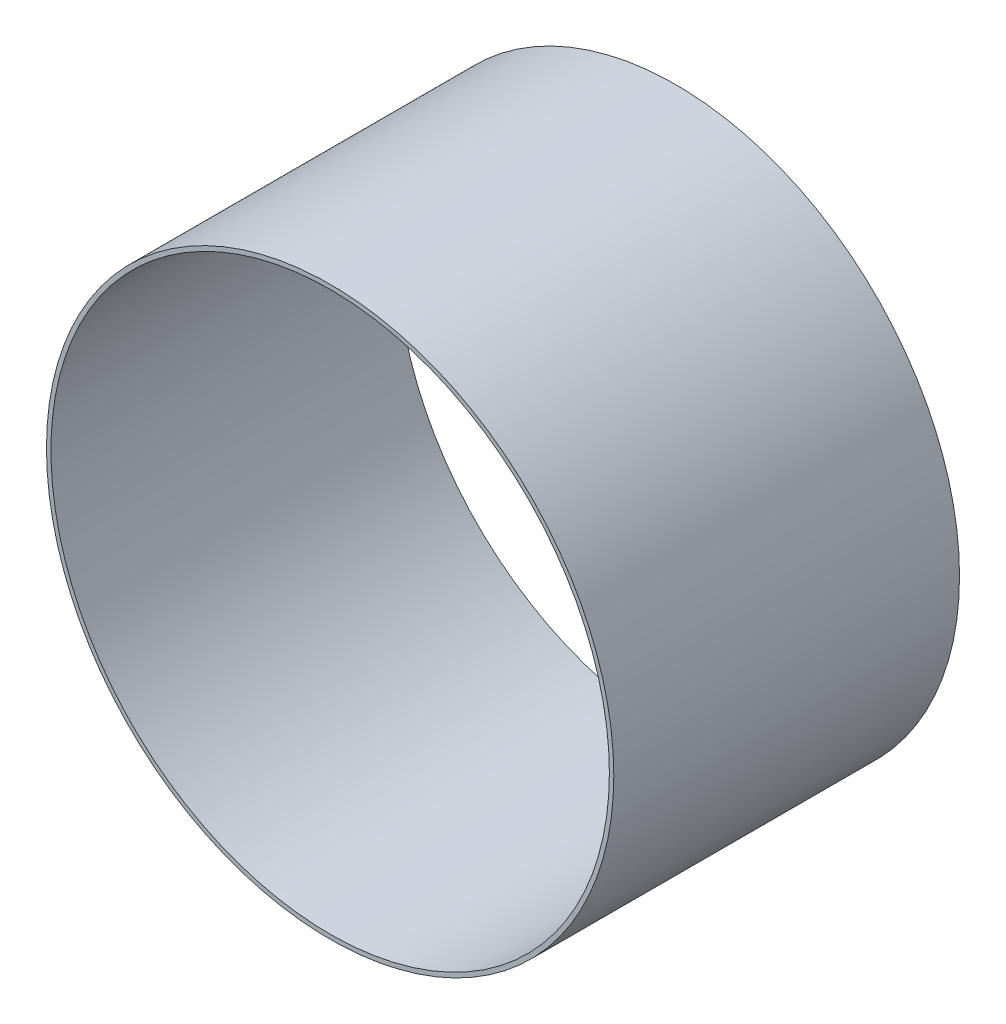
from build123d import *

# Parameters (mm, degrees)
CROQUIS1_R              = 12.8
CROQUIS1_R_2            = 12.6
SALIENTE_EXTRUIR1_DEPTH = 15.6


with BuildPart() as part:
    # Croquis1 → Saliente-Extruir1 (new body)
    with BuildSketch(Plane.XY):
        Circle(CROQUIS1_R)
        Circle(CROQUIS1_R_2, mode=Mode.SUBTRACT)
    extrude(amount=SALIENTE_EXTRUIR1_DEPTH)


solid = part.part
